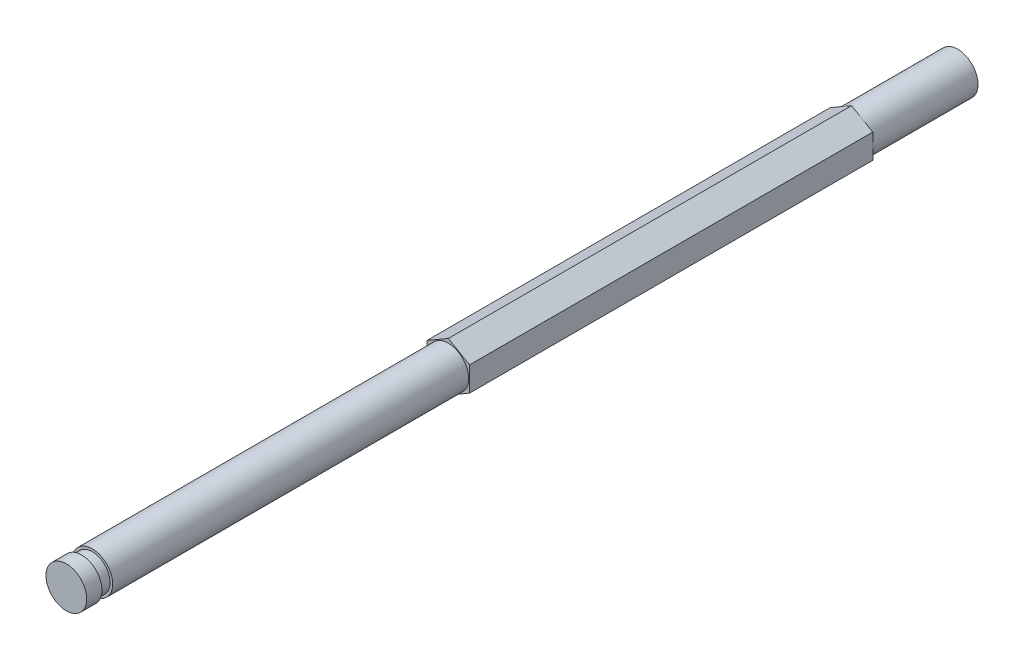
from build123d import *

# Parameters (mm, degrees)
BOSS_EXTRUDE1_DEPTH = 133.35
SKETCH3_OUTSIDE_W   = 35.09
SKETCH3_OUTSIDE_H   = 36.072
SKETCH3_OUTSIDE_R   = 3.048
CUT_EXTRUDE1_DEPTH  = 57.15
SKETCH4_OUTSIDE_W   = 35.09
SKETCH4_OUTSIDE_H   = 36.072
SKETCH4_OUTSIDE_R   = 3.048
CUT_EXTRUDE2_DEPTH  = 15.875
SKETCH5_OUTSIDE_W   = 35.09
SKETCH5_OUTSIDE_H   = 36.072
SKETCH5_OUTSIDE_R   = 2.667
CUT_EXTRUDE3_DEPTH  = 1.6002


with BuildPart() as part:
    # Sketch2 → Boss-Extrude1 (new body)
    with BuildSketch(Plane.XY):
        Polygon((0, 3.666174209), (-3.175, 1.833087105), (-3.175, -1.833087105), (0, -3.666174209), (3.175, -1.833087105), (3.175, 1.833087105), align=None)
    extrude(amount=BOSS_EXTRUDE1_DEPTH)

    # Sketch3 outside → Cut-Extrude1 (cut)
    with BuildSketch(Plane.XY.offset(133.35)):
        Rectangle(SKETCH3_OUTSIDE_W, SKETCH3_OUTSIDE_H)
        Circle(SKETCH3_OUTSIDE_R, mode=Mode.SUBTRACT)
    extrude(amount=-CUT_EXTRUDE1_DEPTH, mode=Mode.SUBTRACT)

    # Sketch4 outside → Cut-Extrude2 (cut)
    with BuildSketch(Plane(origin=(0, 0, 0), x_dir=(-1, 0, 0), z_dir=(0, 0, -1))):
        Rectangle(SKETCH4_OUTSIDE_W, SKETCH4_OUTSIDE_H)
        Circle(SKETCH4_OUTSIDE_R, mode=Mode.SUBTRACT)
    extrude(amount=-CUT_EXTRUDE2_DEPTH, mode=Mode.SUBTRACT)

    # Sketch5 outside → Cut-Extrude3 (cut)
    with BuildSketch(Plane.XY.offset(131.064)):
        Rectangle(SKETCH5_OUTSIDE_W, SKETCH5_OUTSIDE_H)
        Circle(SKETCH5_OUTSIDE_R, mode=Mode.SUBTRACT)
    extrude(amount=-CUT_EXTRUDE3_DEPTH, mode=Mode.SUBTRACT)


solid = part.part
